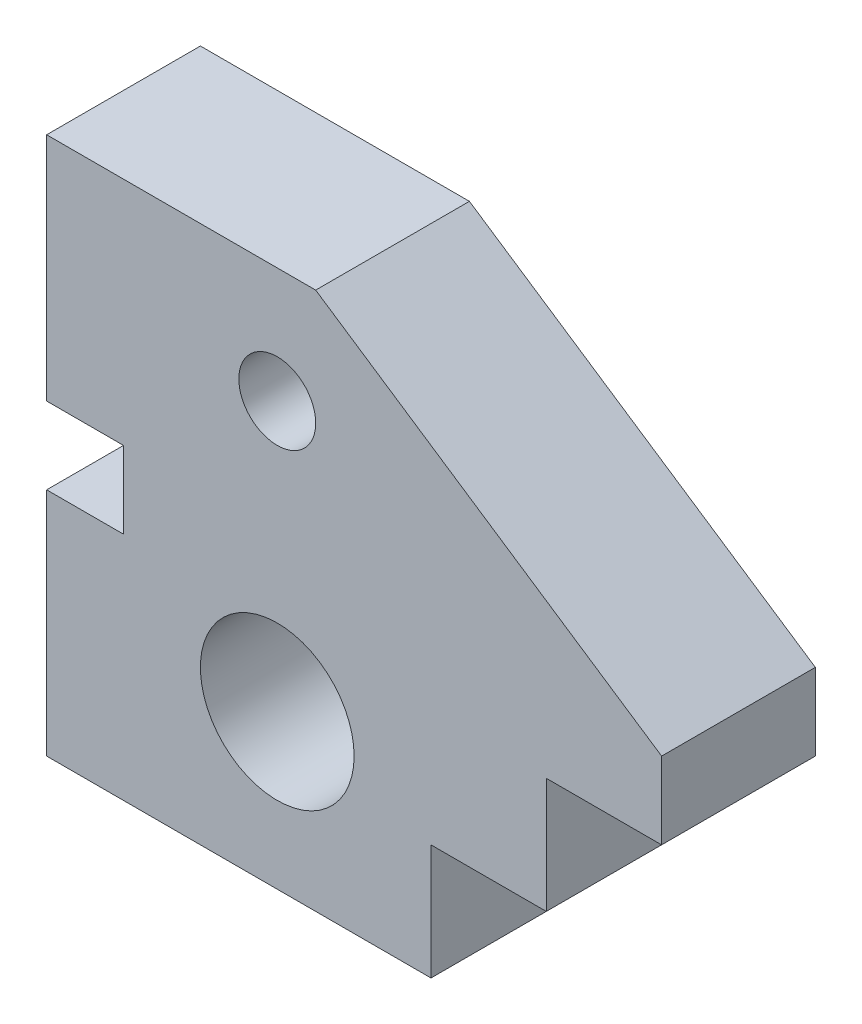
from build123d import *

# Parameters (mm, degrees)
SKETCH1_R           = 10
SKETCH1_R_2         = 5
BOSS_EXTRUDE3_DEPTH = 20


with BuildPart() as part:
    # Sketch1 → Boss-Extrude3 (new body)
    with BuildSketch(Plane.XY):
        Polygon((-28.577015359, 8.156649179), (-28.577015359, 0.131238945), (-28.577015359, 0), (-28.577015359, -21.843350821), (21.422984641, -21.843350821), (21.422984641, -6.843350821), (36.422984641, -6.843350821), (36.422984641, 8.156649179), (51.422984641, 8.156649179), (51.422984641, 18.156649179), (6.422984641, 48.156649179), (-28.577015359, 48.156649179), (-28.577015359, 18.156649179), (-18.577015359, 18.156649179), (-18.577015359, 8.156649179), align=None)
        with Locations((1.422984641, -1.843350821)):
            Circle(SKETCH1_R, mode=Mode.SUBTRACT)
        with Locations((1.422984641, 33.156649179)):
            Circle(SKETCH1_R_2, mode=Mode.SUBTRACT)
    extrude(amount=BOSS_EXTRUDE3_DEPTH)


solid = part.part
